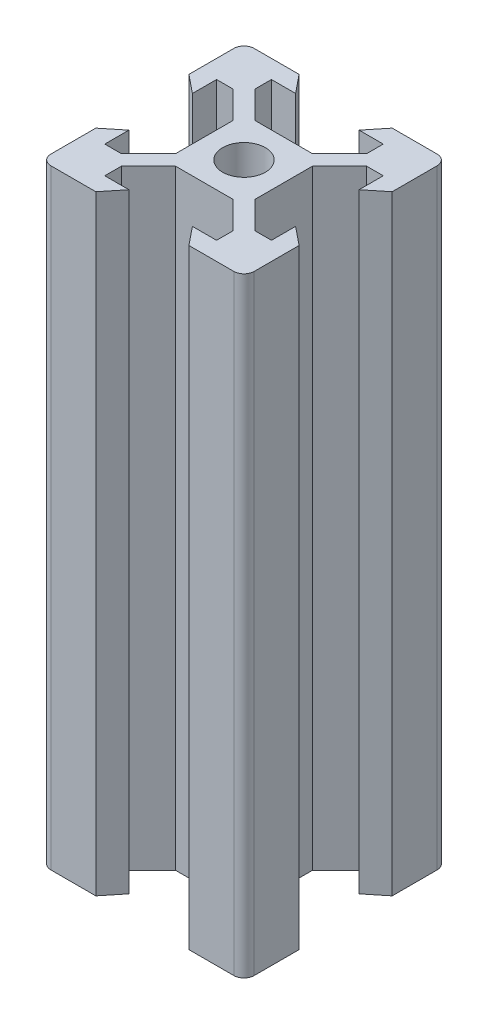
from build123d import *

# Parameters (mm, degrees)
SKETCH1_R           = 2.1
BOSS_EXTRUDE1_DEPTH = 60


with BuildPart() as part:
    # Sketch1 → Boss-Extrude1 (new body)
    with BuildSketch(Plane(origin=(0, 0, 0), x_dir=(1, 0, 0), z_dir=(0, 1, 0))):
        with BuildLine():
            Line((-5.5, 8.2), (-3.125, 8.2))
            Line((-3.125, 8.2), (-4.58, 10))
            Line((-4.58, 10), (-9, 10))
            ThreePointArc((-9, 10), (-9.707106781, 9.707106781), (-10, 9))
            Line((-10, 9), (-10, 4.58))
            Line((-10, 4.58), (-8.2, 3.125))
            Line((-8.2, 3.125), (-8.2, 5.5))
            Line((-8.2, 5.5), (-6.56, 5.5))
            Line((-6.56, 5.5), (-3.9, 2.84))
            Line((-3.9, 2.84), (-3.9, -2.84))
            Line((-3.9, -2.84), (-6.56, -5.5))
            Line((-6.56, -5.5), (-8.2, -5.5))
            Line((-8.2, -5.5), (-8.2, -3.125))
            Line((-8.2, -3.125), (-10, -4.58))
            Line((-10, -4.58), (-10, -9))
            ThreePointArc((-10, -9), (-9.707106781, -9.707106781), (-9, -10))
            Line((-9, -10), (-4.58, -10))
            Line((-4.58, -10), (-3.125, -8.2))
            Line((-3.125, -8.2), (-5.5, -8.2))
            Line((-5.5, -8.2), (-5.5, -6.56))
            Line((-5.5, -6.56), (-2.84, -3.9))
            Line((-2.84, -3.9), (2.84, -3.9))
            Line((2.84, -3.9), (5.5, -6.56))
            Line((5.5, -6.56), (5.5, -8.2))
            Line((5.5, -8.2), (3.125, -8.2))
            Line((3.125, -8.2), (4.58, -10))
            Line((4.58, -10), (9, -10))
            ThreePointArc((9, -10), (9.707106781, -9.707106781), (10, -9))
            Line((10, -9), (10, -4.58))
            Line((10, -4.58), (8.2, -3.125))
            Line((8.2, -3.125), (8.2, -5.5))
            Line((8.2, -5.5), (6.56, -5.5))
            Line((6.56, -5.5), (3.9, -2.84))
            Line((3.9, -2.84), (3.9, 2.84))
            Line((3.9, 2.84), (6.56, 5.5))
            Line((6.56, 5.5), (8.2, 5.5))
            Line((8.2, 5.5), (8.2, 3.125))
            Line((8.2, 3.125), (10, 4.58))
            Line((10, 4.58), (10, 9))
            ThreePointArc((10, 9), (9.707106781, 9.707106781), (9, 10))
            Line((9, 10), (4.58, 10))
            Line((4.58, 10), (3.125, 8.2))
            Line((3.125, 8.2), (5.5, 8.2))
            Line((5.5, 8.2), (5.5, 6.56))
            Line((5.5, 6.56), (2.84, 3.9))
            Line((2.84, 3.9), (-2.84, 3.9))
            Line((-2.84, 3.9), (-5.5, 6.56))
            Line((-5.5, 6.56), (-5.5, 8.2))
        make_face()
        Circle(SKETCH1_R, mode=Mode.SUBTRACT)
    extrude(amount=BOSS_EXTRUDE1_DEPTH)


solid = part.part
